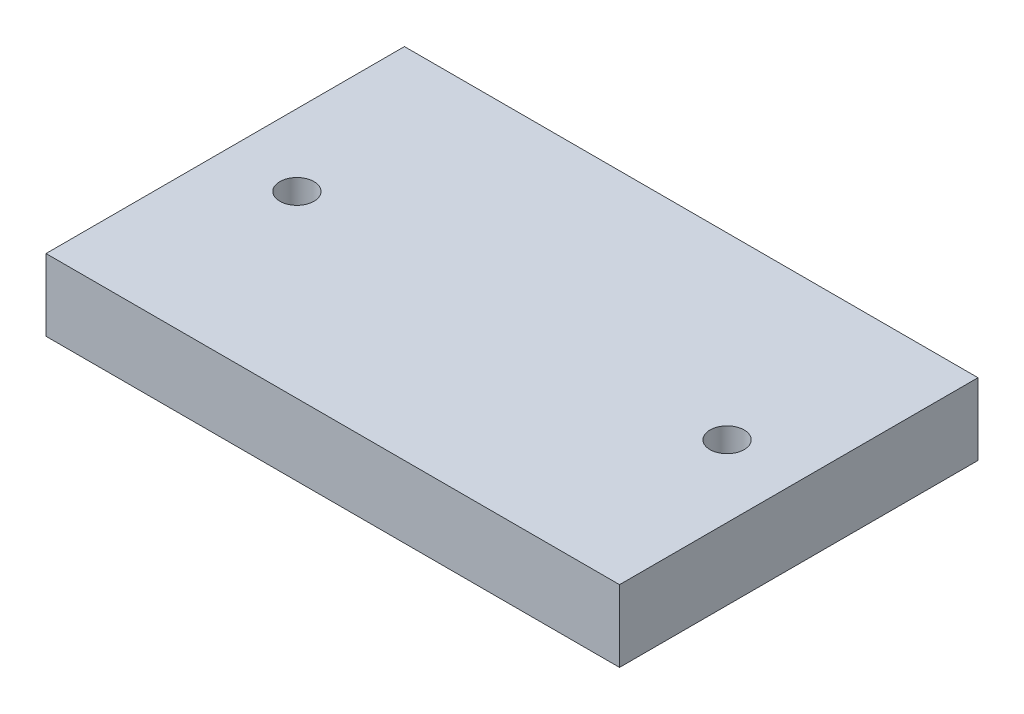
from build123d import *

# Parameters (mm, degrees)
SKETCH1_W           = 80
SKETCH1_H           = 50
BOSS_EXTRUDE1_DEPTH = 10
SKETCH2_R           = 2.38125
CUT_EXTRUDE1_DEPTH  = 10


with BuildPart() as part:
    # Sketch1 → Boss-Extrude1 (new body)
    with BuildSketch(Plane(origin=(0, 0, 0), x_dir=(1, 0, 0), z_dir=(0, 1, 0))):
        Rectangle(SKETCH1_W, SKETCH1_H)
    extrude(amount=BOSS_EXTRUDE1_DEPTH)

    # Sketch2 → Cut-Extrude1 (cut)
    with BuildSketch(Plane(origin=(0, 10, 0), x_dir=(1, 0, 0), z_dir=(0, 1, 0))):
        with Locations((-30, 0)):
            Circle(SKETCH2_R)
        with Locations((30, 0)):
            Circle(SKETCH2_R)
    extrude(amount=-CUT_EXTRUDE1_DEPTH, mode=Mode.SUBTRACT)


solid = part.part
